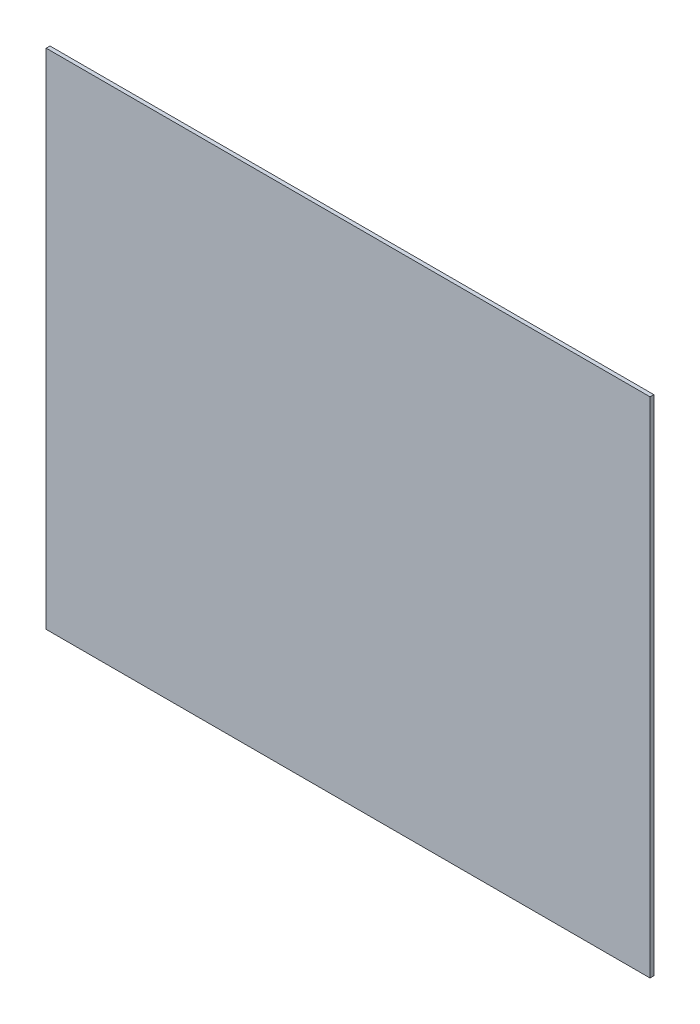
from build123d import *

# Parameters (mm, degrees)
SKETCH1_W           = 475
SKETCH1_H           = 396
BOSS_EXTRUDE1_DEPTH = 3


with BuildPart() as part:
    # Sketch1 → Boss-Extrude1 (new body)
    with BuildSketch(Plane.XY):
        Rectangle(SKETCH1_W, SKETCH1_H)
    extrude(amount=BOSS_EXTRUDE1_DEPTH)


solid = part.part
